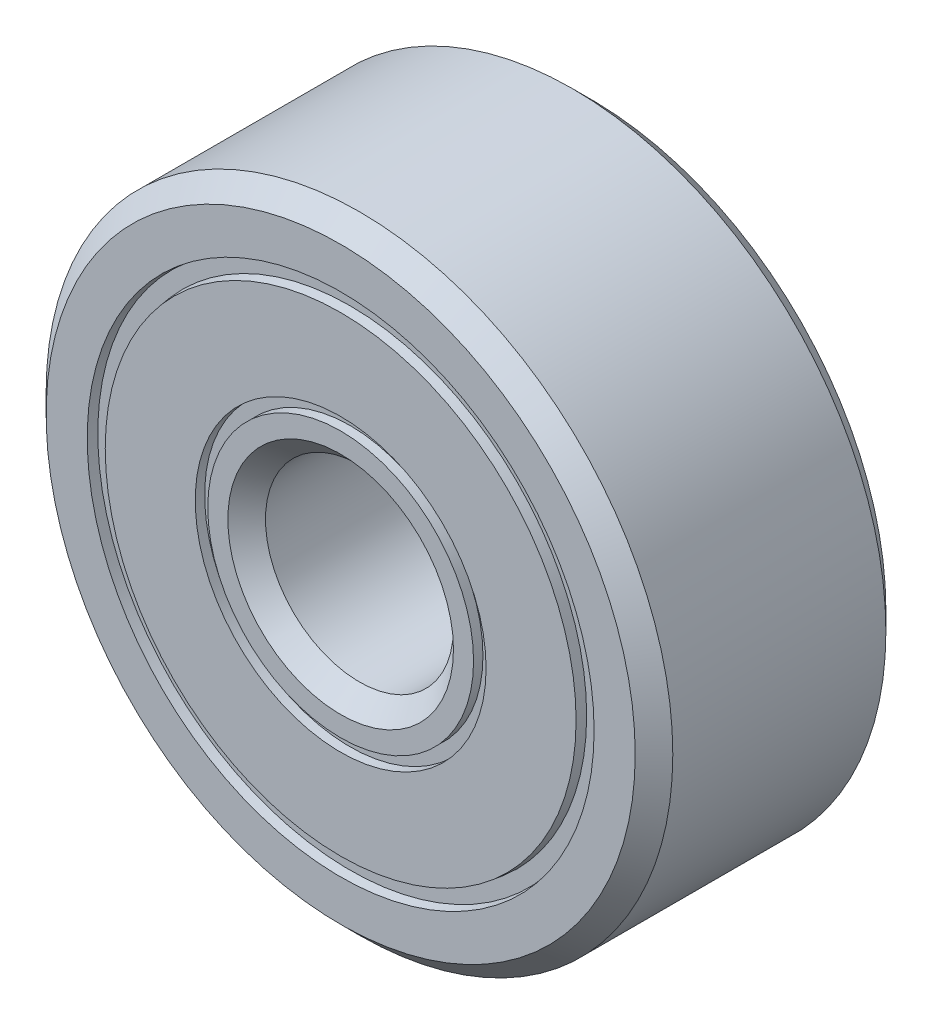
from build123d import *

# Parameters (mm, degrees)
CROQUIS1_R              = 5
CROQUIS1_R_2            = 1.5
SALIENTE_EXTRUIR1_DEPTH = 4
CHAFL_N1_SIZE           = 0.3
CROQUIS2_W              = 1
CROQUIS2_H              = 0.2


with BuildPart() as part:
    # Croquis1 → Saliente-Extruir1 (new body)
    with BuildSketch(Plane.XY):
        Circle(CROQUIS1_R)
        Circle(CROQUIS1_R_2, mode=Mode.SUBTRACT)
    extrude(amount=SALIENTE_EXTRUIR1_DEPTH)

    # Chaflán1
    chafl_n1_edges = [part.edges().sort_by_distance(p)[0] for p in [
        (-5, 0, 0),
        (-5, 0, 4),
        (-1.5, 0, 0),
        (-1.5, 0, 4),
    ]]
    chamfer(chafl_n1_edges, length=CHAFL_N1_SIZE)

    # Croquis2 → Cortar-Revolución1 (revolve, cut)
    with BuildSketch(Plane(origin=(0, 0, 0), x_dir=(0, 0, -1), z_dir=(1, 0, 0))):
        Polygon((-4.85, 4.150466692), (-3.85, 4.025466692), (-3.85, 3.775466692), (-4.85, 3.650466692), align=None)
        Polygon((0.85, 3.650466692), (0.85, 4.150466692), (-0.15, 4.025466692), (-0.15, 3.775466692), align=None)
        with Locations((-4.35, 2.220733596)):
            Rectangle(CROQUIS2_W, CROQUIS2_H)
        with Locations((0.35, 2.220733596)):
            Rectangle(CROQUIS2_W, CROQUIS2_H)
    revolve(axis=Axis((0, 0, 12.411349243), (0, 0, -1)), mode=Mode.SUBTRACT)


solid = part.part
